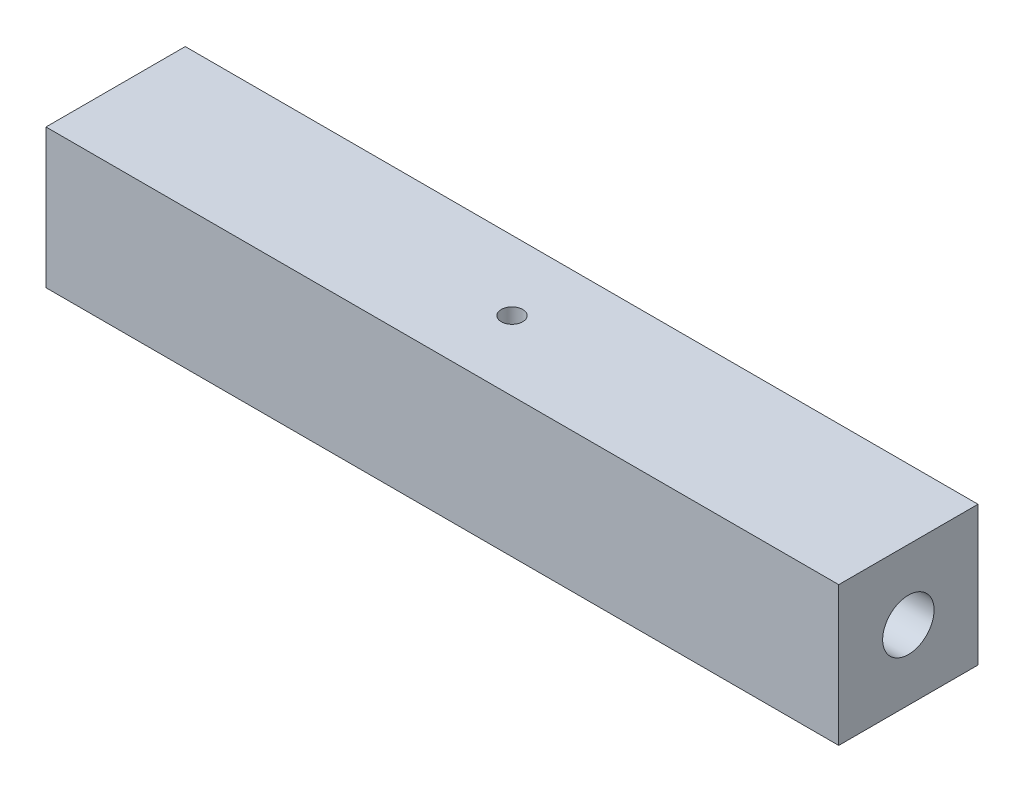
from build123d import *

# Parameters (mm, degrees)
SKETCH1_W           = 16.51
SKETCH1_H           = 16.51
BOSS_EXTRUDE1_DEPTH = 46.99
SKETCH2_R           = 3.048
CUT_EXTRUDE1_DEPTH  = 17.78
CUT_EXTRUDE2_START  = 8.255
SKETCH3_R           = 1.27
CUT_EXTRUDE2_DEPTH  = 17.51


with BuildPart() as part:
    # Sketch1 → Boss-Extrude1 (new body, symmetric)
    with BuildSketch(Plane(origin=(0, 0, 0), x_dir=(0, 0, -1), z_dir=(1, 0, 0))):
        Rectangle(SKETCH1_W, SKETCH1_H)
    extrude(amount=BOSS_EXTRUDE1_DEPTH, both=True)

    # Sketch2 → Cut-Extrude1 (cut)
    with BuildSketch(Plane(origin=(46.99, 0, 0), x_dir=(0, 0, -1), z_dir=(1, 0, 0))):
        Circle(SKETCH2_R)
    cut_extrude1 = extrude(amount=-CUT_EXTRUDE1_DEPTH, mode=Mode.SUBTRACT)

    # Mirror1: Cut-Extrude1 across plane
    add(cut_extrude1.mirror(Plane(origin=(0, 0, 0), x_dir=(0, 0, 1), z_dir=(1, 0, 0))), mode=Mode.SUBTRACT)

    # Sketch3 → Cut-Extrude2 (cut, through all)
    with BuildSketch(Plane(origin=(0, 0, 0), x_dir=(1, 0, 0), z_dir=(0, 1, 0)).offset(CUT_EXTRUDE2_START)):
        Circle(SKETCH3_R)
    extrude(amount=-CUT_EXTRUDE2_DEPTH, mode=Mode.SUBTRACT)


solid = part.part
